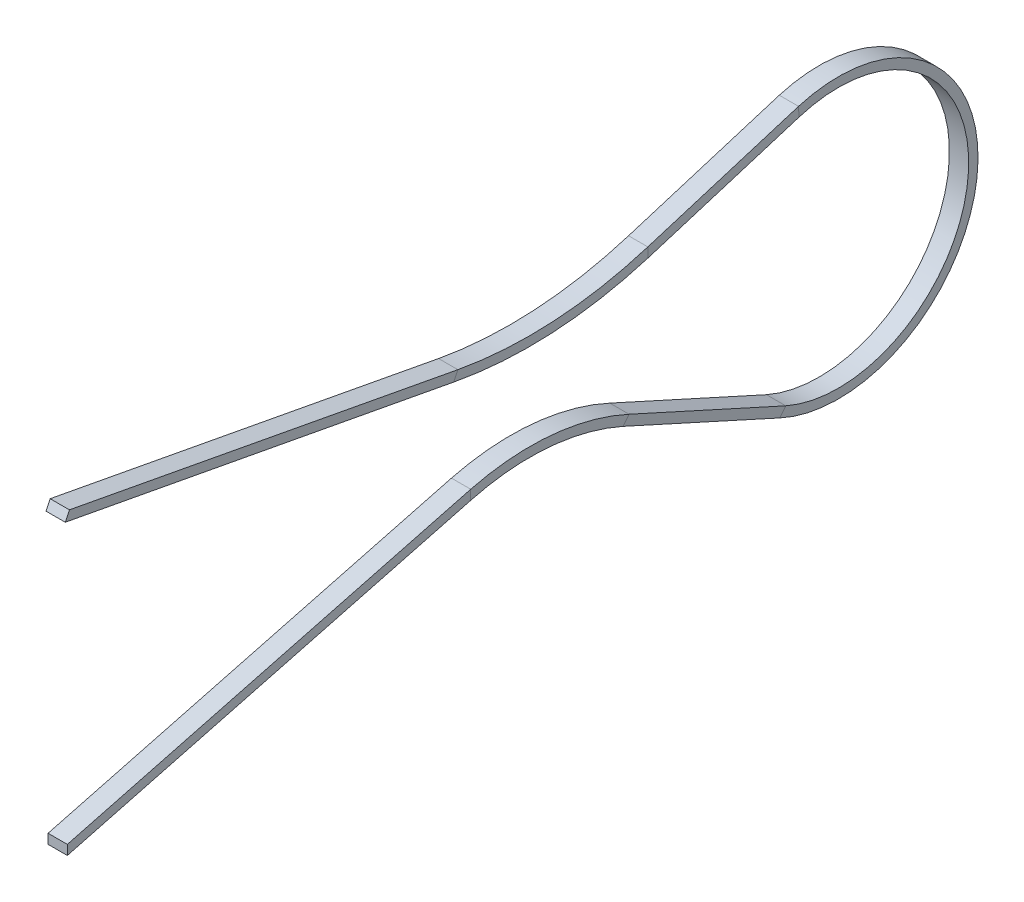
from build123d import *

# Parameters (mm, degrees)
IZIM1_W = 1
IZIM1_H = 0.5


with BuildPart() as part:
    # Süpür1: sweep along a path in Çizim2
    with BuildLine(Plane(origin=(0, 0, 0), x_dir=(0, 0, -1), z_dir=(1, 0, 0))) as s_p_r1_path:
        Line((0, 0), (20.925351885, 5.491949727))
        ThreePointArc((20.925351885, 5.491949727), (25.014077523, 5.844705367), (28.985134799, 4.808936092))
        Line((28.985134799, 4.808936092), (37.108981933, 1.124891018))
        ThreePointArc((37.108981933, 1.124891018), (46.985809894, 7.054511358), (37.942195071, 14.190697936))
        Line((37.942195071, 14.190697936), (30.12359745, 11.785993841))
        ThreePointArc((30.12359745, 11.785993841), (25.171390105, 10.89789359), (20.150614238, 11.22175983))
        Line((20.150614238, 11.22175983), (0, 15))
    # Çizim1 → Süpür1 (sweep)
    with BuildSketch(Plane.XY):
        Rectangle(IZIM1_W, IZIM1_H)
    sweep(path=s_p_r1_path.line)


solid = part.part
